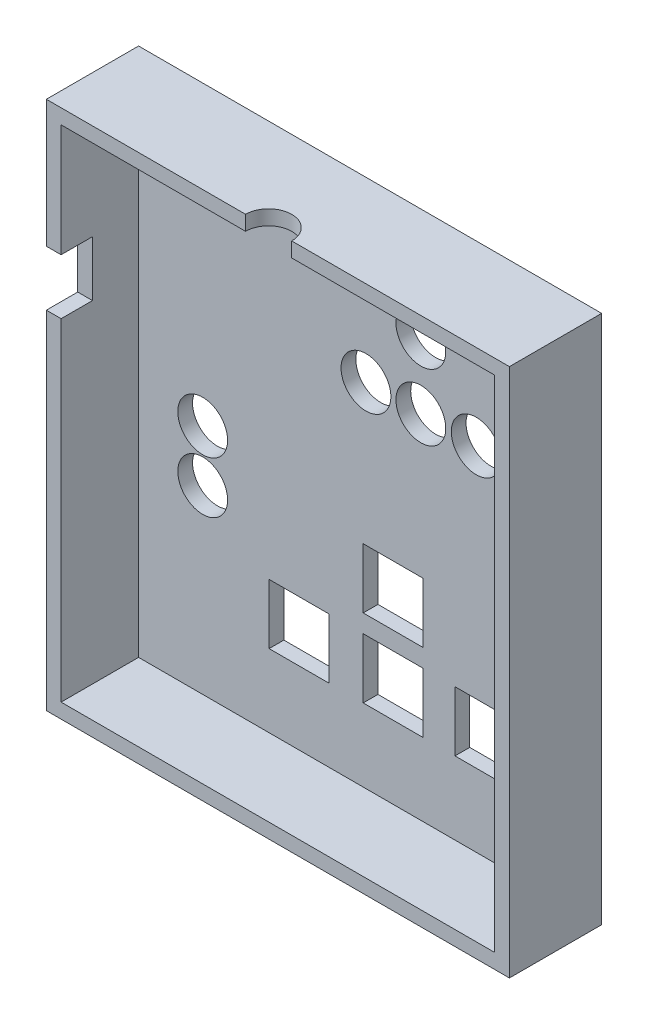
from build123d import *

# Parameters (mm, degrees)
SKETCH1_W           = 50.2
SKETCH1_H           = 57.4
BOSS_EXTRUDE1_DEPTH = 10
SHELL1_T            = -1.6
SKETCH2_R           = 2.7
CUT_EXTRUDE1_DEPTH  = 10
SKETCH3_W           = 3.4
SKETCH3_H           = 6
CUT_EXTRUDE2_DEPTH  = 10
SKETCH4_R           = 2.5
CUT_EXTRUDE3_DEPTH  = 10
SKETCH5_W           = 6.5
SKETCH5_H           = 6.5
CUT_EXTRUDE4_DEPTH  = 10


with BuildPart() as part:
    # Sketch1 → Boss-Extrude1 (new body)
    with BuildSketch(Plane.XY):
        with Locations((25.1, 24.846666667)):
            Rectangle(SKETCH1_W, SKETCH1_H)
    extrude(amount=BOSS_EXTRUDE1_DEPTH)

    # Shell1
    shell1_openings = [part.faces().sort_by_distance(p)[0] for p in [
        (25.1, 24.846666667, 10),
    ]]
    offset(amount=SHELL1_T, openings=shell1_openings, kind=Kind.INTERSECTION)

    # Sketch2 → Cut-Extrude1 (cut)
    with BuildSketch(Plane(origin=(0, 0, 0), x_dir=(-1, 0, 0), z_dir=(0, 0, -1))):
        with Locations((-8.55, 17.346666667)):
            Circle(SKETCH2_R)
        with Locations((-8.55, 22.946666667)):
            Circle(SKETCH2_R)
        with Locations((-44.15, 35.896666667)):
            Circle(SKETCH2_R)
        with Locations((-26.25, 35.896666667)):
            Circle(SKETCH2_R)
        with Locations((-38.2, 35.896666667)):
            Circle(SKETCH2_R)
        with Locations((-32.2, 35.896666667)):
            Circle(SKETCH2_R)
        with Locations((-32.2, 43.096666667)):
            Circle(SKETCH2_R)
    extrude(amount=-CUT_EXTRUDE1_DEPTH, mode=Mode.SUBTRACT)

    # Sketch3 → Cut-Extrude2 (cut)
    with BuildSketch(Plane.ZY):
        with Locations((8.3, 36.746666667)):
            Rectangle(SKETCH3_W, SKETCH3_H)
    extrude(amount=-CUT_EXTRUDE2_DEPTH, mode=Mode.SUBTRACT)

    # Sketch4 → Cut-Extrude3 (cut)
    with BuildSketch(Plane(origin=(0, 53.546666667, 0), x_dir=(1, 0, 0), z_dir=(0, 1, 0))):
        with Locations((24.1, -10)):
            Circle(SKETCH4_R)
    extrude(amount=-CUT_EXTRUDE3_DEPTH, mode=Mode.SUBTRACT)

    # Sketch5 → Cut-Extrude4 (cut)
    with BuildSketch(Plane(origin=(0, 0, 0), x_dir=(-1, 0, 0), z_dir=(0, 0, -1))):
        with Locations((-39.15, 8.896666667)):
            Rectangle(SKETCH5_W, SKETCH5_H)
        with Locations((-29.2, 8.896666667)):
            Rectangle(SKETCH5_W, SKETCH5_H)
        with Locations((-19, 8.896666667)):
            Rectangle(SKETCH5_W, SKETCH5_H)
        with Locations((-29.2, 17.346666667)):
            Rectangle(SKETCH5_W, SKETCH5_H)
    extrude(amount=-CUT_EXTRUDE4_DEPTH, mode=Mode.SUBTRACT)


solid = part.part
